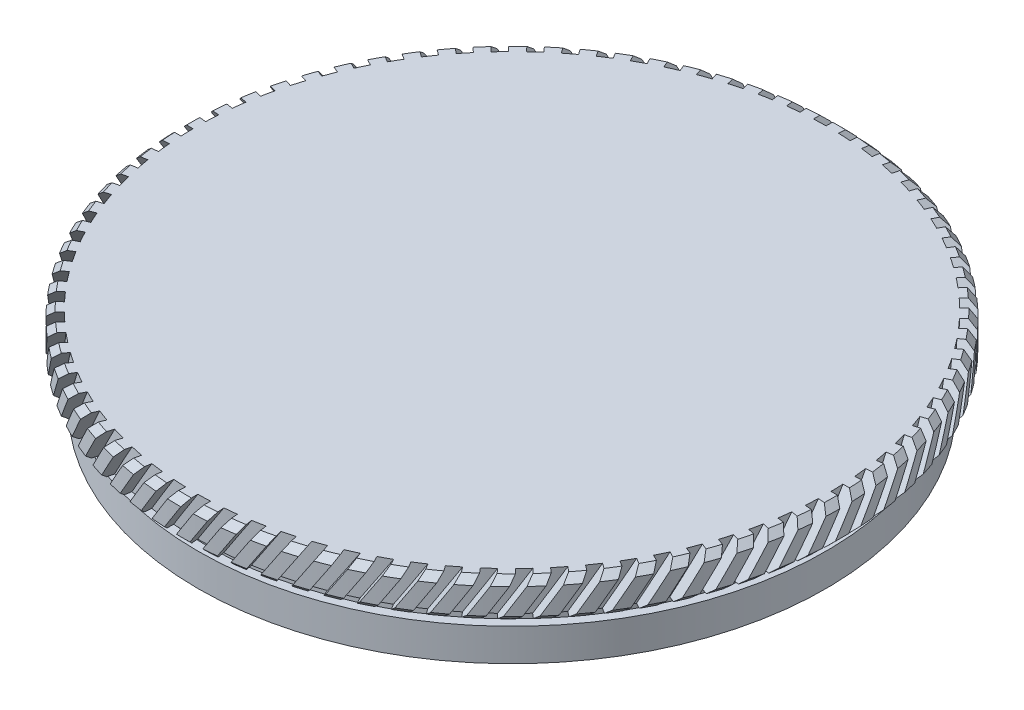
from build123d import *

# Parameters (mm, degrees)
CHAMFER_1_SIZE           = 0.5
CUT_EXTRUDE_1_REACH      = 74.056
CUT_EXTRUDE_1_END_RADIUS = 24.4
CUT_EXTRUDE_START        = 30
PATTERN_CIRCULAR_2_COUNT = 80


with BuildPart() as part:
    # 草图1 → 旋转2 (revolve)
    with BuildSketch(Plane.XY, mode=Mode.PRIVATE) as revolve_2_sk:
        Polygon((0, 21.871257405), (25.4, 21.871257405), (25.4, 18.871257405), (23.5, 18.871257405), (23.5, 17.871257405), (24.2, 17.871257405), (24.2, 15.371257405), (21, 15.371257405), (21, 18.871257405), (0, 18.871257405), align=None)
    revolve(revolve_2_sk.sketch.rotate(Axis((0, 66.628762136, 0), (0, -1, 0)), 90), axis=Axis((0, 66.628762136, 0), (0, -1, 0)))

    # 倒角1
    chamfer_1_edges = [part.edges().sort_by_distance(p)[0] for p in [
        (0, 21.871257405, -25.4),
        (0, 18.871257405, -25.4),
    ]]
    chamfer(chamfer_1_edges, length=CHAMFER_1_SIZE)

    # 切除-拉伸1: up to this cylinder (the profile starts outside it)
    cut_extrude_1_end = Plane(origin=(0, 18.072086, 0), z_dir=(0, 1, 0)) * Cylinder(CUT_EXTRUDE_1_END_RADIUS, 197.912, mode=Mode.PRIVATE)
    # 草图2 → 切除-拉伸1 (cut, up to the surface)
    with BuildSketch(Plane.XY.offset(CUT_EXTRUDE_START), mode=Mode.PRIVATE) as cut_extrude_1_sk1:
        Polygon((1.108168834, 23.303253722), (-5.339513804, 13.273525174), (-4.666571024, 12.840919101), (1.781111614, 22.870647649), align=None)
    cut_extrude_1_tool1 = extrude(cut_extrude_1_sk1.sketch, amount=-CUT_EXTRUDE_1_REACH, mode=Mode.PRIVATE) - cut_extrude_1_end
    cut_extrude_1 = cut_extrude_1_tool1.solids().sort_by_distance((-1.779201, 18.072086, 30))[0]
    add(cut_extrude_1, mode=Mode.SUBTRACT)

    # 阵列(圆周)2: 切除-拉伸1 ×80 about axis
    pattern_circular_2_axis = Axis((0, 0, 0), (0, 1, 0))
    for i in range(1, PATTERN_CIRCULAR_2_COUNT):
        add(cut_extrude_1.rotate(pattern_circular_2_axis, i * 360 / PATTERN_CIRCULAR_2_COUNT), mode=Mode.SUBTRACT)


solid = part.part
